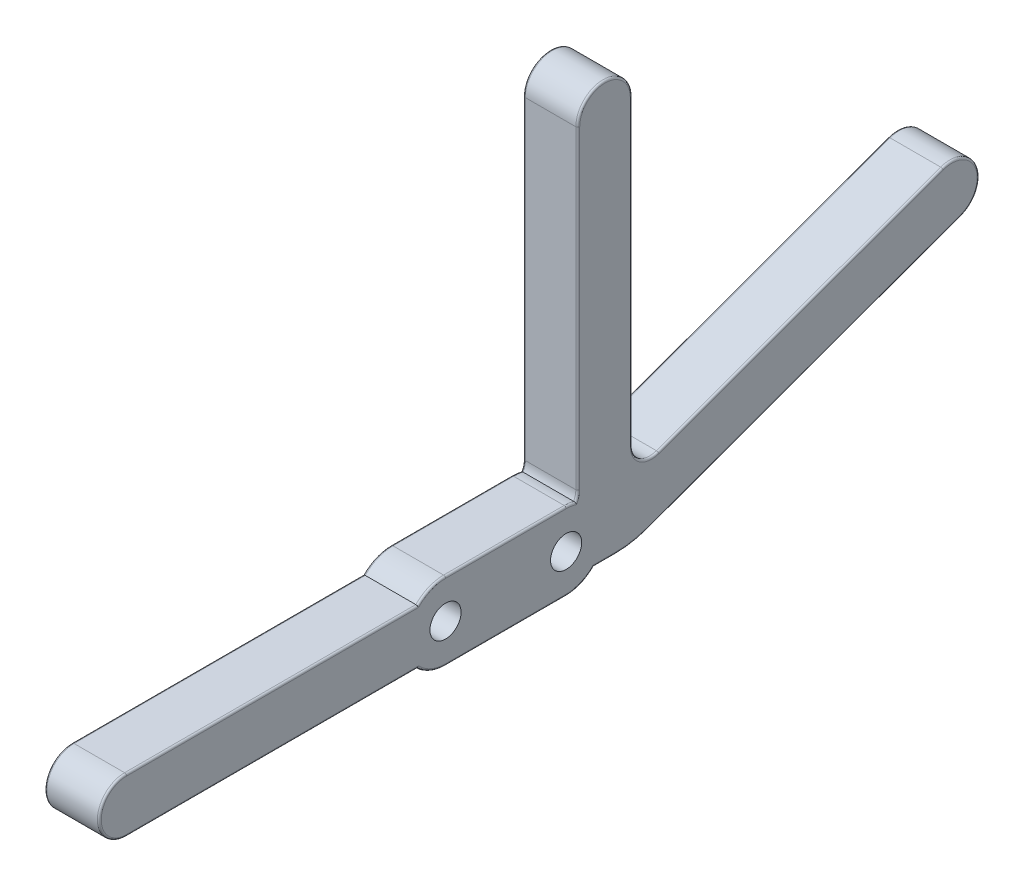
from build123d import *

# Parameters (mm, degrees)
BOSS_EXTRUDE1_DEPTH = 7
BOSS_EXTRUDE2_DEPTH = 7
FILLET1_R           = 0.25
SKETCH4_R           = 2
CUT_EXTRUDE2_DEPTH  = 7
SKETCH3_R           = 1.125
CUT_EXTRUDE1_DEPTH  = 5.5


with BuildPart() as part:
    # Sketch1 → Boss-Extrude1 (new body)
    with BuildSketch(Plane(origin=(0, 0, 0), x_dir=(0, 0, -1), z_dir=(1, 0, 0))):
        with BuildLine():
            Line((-58, 0), (-2.5, 0))
            ThreePointArc((-2.5, 0), (-0.732233047, 0.732233047), (0, 2.5))
            Line((0, 2.5), (0, 42.901452767))
            ThreePointArc((0, 42.901452767), (3.5, 46.401452767), (7, 42.901452767))
            Line((7, 42.901452767), (7, 4.019614424))
            ThreePointArc((7, 4.019614424), (8.066058909, 1.971734313), (10.355050358, 1.670382872))
            Line((10.355050358, 1.670382872), (46.892026932, 14.968754795))
            ThreePointArc((46.892026932, 14.968754795), (51.378021606, 12.876901124), (49.286167935, 8.39090645))
            Line((49.286167935, 8.39090645), (8.988317951, -6.276311449))
            ThreePointArc((8.988317951, -6.276311449), (6.967854364, -6.817693036), (4.884076231, -7))
            Line((4.884076231, -7), (-58, -7))
            ThreePointArc((-58, -7), (-61.5, -3.5), (-58, 0))
        make_face()
    extrude(amount=BOSS_EXTRUDE1_DEPTH)

    # Sketch2 → Boss-Extrude2 (add)
    with BuildSketch(Plane(origin=(7, 0, 0), x_dir=(0, 0, -1), z_dir=(1, 0, 0))):
        with BuildLine():
            Line((-17, 1.5), (-1.5, 1.5))
            ThreePointArc((-1.5, 1.5), (3.5, -3.5), (-1.5, -8.5))
            Line((-1.5, -8.5), (-17, -8.5))
            ThreePointArc((-17, -8.5), (-22, -3.5), (-17, 1.5))
        make_face()
    extrude(amount=-BOSS_EXTRUDE2_DEPTH)

    # Fillet1
    fillet1_edges = [part.edges().sort_by_distance(p)[0] for p in [
        (7, -6.817693036, -6.967854364),
        (0, 1.907658596, 0.071187191),
        (0, 22.700726384, 0),
        (0, 46.401452767, -3.5),
        (0, 23.460533596, -7),
        (0, 1.971734313, -8.066058909),
        (7, 1.0572975, -29.137242943),
        (0, 8.319568834, -28.623538645),
        (0, 12.876901124, -51.378021606),
        (0, 1.0572975, -29.137242943),
        (0, -6.817693036, -6.967854364),
        (0, -7, 39.285357107),
        (0, -3.5, 61.5),
        (7, 12.876901124, -51.378021606),
        (7, 8.319568834, -28.623538645),
        (7, 1.971734313, -8.066058909),
        (7, 23.460533596, -7),
        (7, 46.401452767, -3.5),
        (7, 22.700726384, 0),
        (7, 1.907658596, 0.071187191),
        (0, 0, 39.285357107),
        (0, -7, -3.477395223),
        (7, -7, -3.477395223),
        (7, 0, 39.285357107),
        (7, -3.5, 61.5),
        (7, -8.109772229, 18.936491673),
        (7, -8.5, 9.25),
        (7, -8.109772229, -0.436491673),
        (7, 1.462119227, 0.885693253),
        (7, 1.5, 9.25),
        (7, 1.109772229, 18.936491673),
        (0, -8.109772229, 18.936491673),
        (0, -8.109772229, -0.436491673),
        (0, -8.5, 9.25),
        (0, 1.462119227, 0.885693253),
        (0, 1.109772229, 18.936491673),
        (0, 1.5, 9.25),
        (7, -7, 39.285357107),
    ]]
    fillet(fillet1_edges, radius=FILLET1_R)

    # Sketch4 → Cut-Extrude2 (cut)
    with BuildSketch(Plane(origin=(0, 0, 0), x_dir=(0, 0, -1), z_dir=(1, 0, 0))):
        with Locations((-17, -3.5)):
            Circle(SKETCH4_R)
        with Locations((-1.5, -3.5)):
            Circle(SKETCH4_R)
    extrude(amount=CUT_EXTRUDE2_DEPTH, mode=Mode.SUBTRACT)

    # Sketch3 → Cut-Extrude1 (cut)
    with BuildSketch(Plane(origin=(0, 0, 0), x_dir=(0, 0, -1), z_dir=(1, 0, 0))):
        with Locations((3.5, 42.901452767)):
            Circle(SKETCH3_R)
        with Locations((48.089097434, 11.679830622)):
            Circle(SKETCH3_R)
        with Locations((-58, -3.5)):
            Circle(SKETCH3_R)
    extrude(amount=CUT_EXTRUDE1_DEPTH, mode=Mode.SUBTRACT)


solid = part.part
